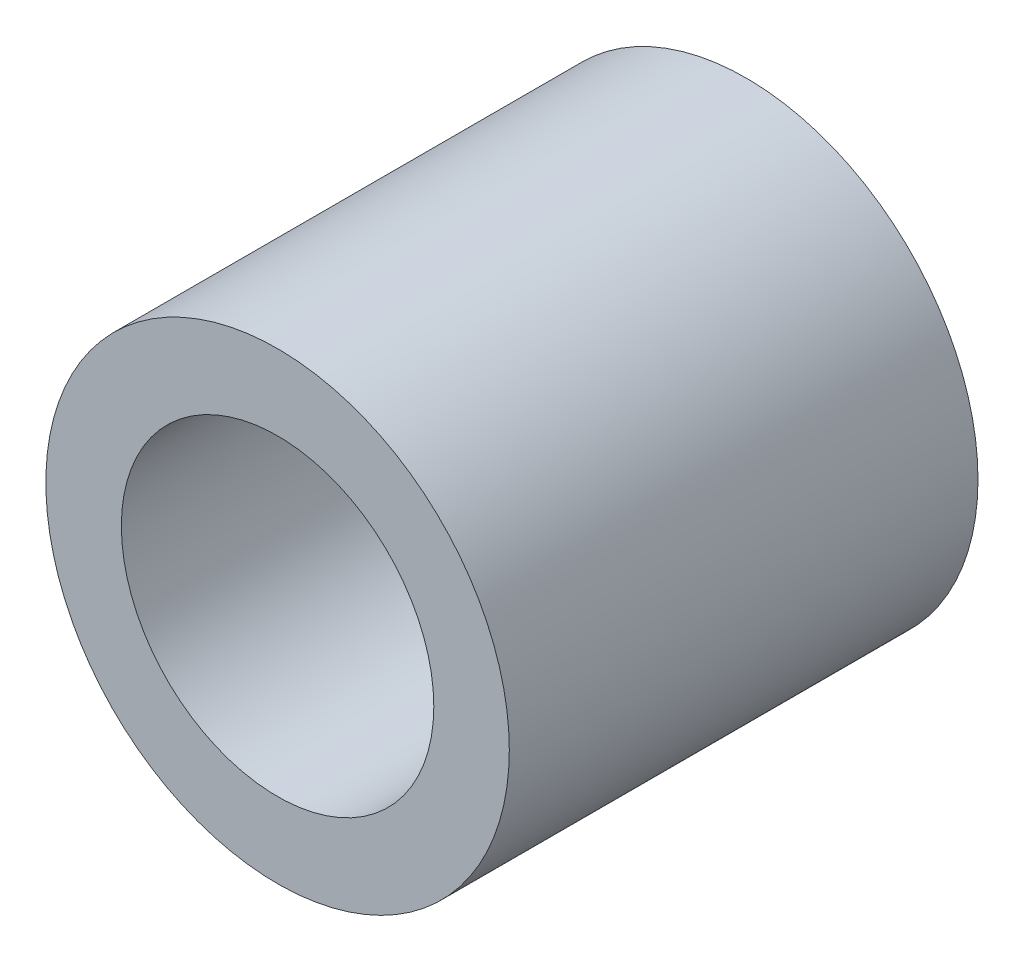
from build123d import *

# Parameters (mm, degrees)
SKETCH_1_R      = 4.45
SKETCH_1_R_2    = 3
EXTRUDE_1_DEPTH = 9


with BuildPart() as part:
    # 草圖1 → 填料-伸長1 (new body)
    with BuildSketch(Plane.XY):
        Circle(SKETCH_1_R)
        Circle(SKETCH_1_R_2, mode=Mode.SUBTRACT)
    extrude(amount=EXTRUDE_1_DEPTH)


solid = part.part
